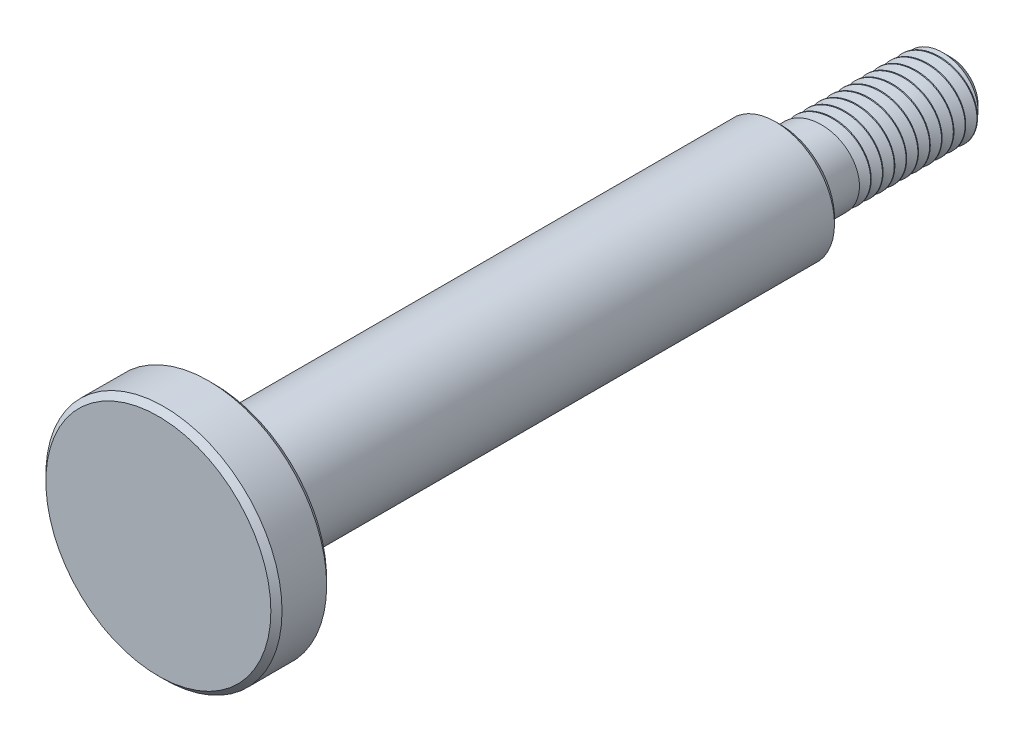
from build123d import *

# Parameters (mm, degrees)
CHAMFER1_SIZE        = 0.3
CHAMFER2_SIZE        = 0.3
CHAMFER3_SIZE        = 0.635
LPATTERN1_COUNT      = 8
LPATTERN1_PITCH      = 0.635
LPATTERN1_COUNT_DIR2 = 2
LPATTERN1_PITCH_DIR2 = 2.54


with BuildPart() as part:
    # Sketch1 → Revolve1 (revolve)
    with BuildSketch(Plane(origin=(0, 0, 0), x_dir=(1, 0, 0), z_dir=(0, 1, 0))):
        Polygon((0, 9.144), (2.0828, 9.144), (2.0828, 0), (3.175, 0), (3.175, -30.47857188), (6.35, -30.47857188), (6.35, -33.47857188), (0, -33.47857188), align=None)
    revolve(axis=Axis((0, 0, 0), (0, 0, -1)))

    # Chamfer1
    chamfer1_edges = [part.edges().sort_by_distance(p)[0] for p in [
        (-6.35, 0, 33.47857188),
        (-3.175, 0, 0),
    ]]
    chamfer(chamfer1_edges, length=CHAMFER1_SIZE)

    # Chamfer2
    chamfer2_edges = [part.edges().sort_by_distance(p)[0] for p in [
        (-6.35, 0, 30.47857188),
    ]]
    chamfer(chamfer2_edges, length=CHAMFER2_SIZE)

    # Chamfer3
    chamfer3_edges = [part.edges().sort_by_distance(p)[0] for p in [
        (-2.0828, 0, -9.144),
    ]]
    chamfer(chamfer3_edges, length=CHAMFER3_SIZE)

    # Sketch3 → 8-32 sim (revolve, cut)
    with BuildSketch(Plane(origin=(0, 0, 0), x_dir=(1, 0, 0), z_dir=(0, 1, 0))):
        Polygon((-2.16053589, 9.201768117), (-2.0828, 8.566768117), (-1.571741814, 8.951589372), align=None)
    f_8_32_sim = revolve(axis=Axis((0, 0, -9.144), (-0.121511603, 0, -0.992590011)), mode=Mode.SUBTRACT)

    # LPattern1: 8-32 sim 8 × 2
    with Locations(*[Vector(0, 0, 1) * (i * LPATTERN1_PITCH) + Vector(0, 0, 1) * (j * LPATTERN1_PITCH_DIR2) for i in range(LPATTERN1_COUNT) for j in range(LPATTERN1_COUNT_DIR2) if (i, j) != (0, 0)]):
        add(f_8_32_sim, mode=Mode.SUBTRACT)


solid = part.part
